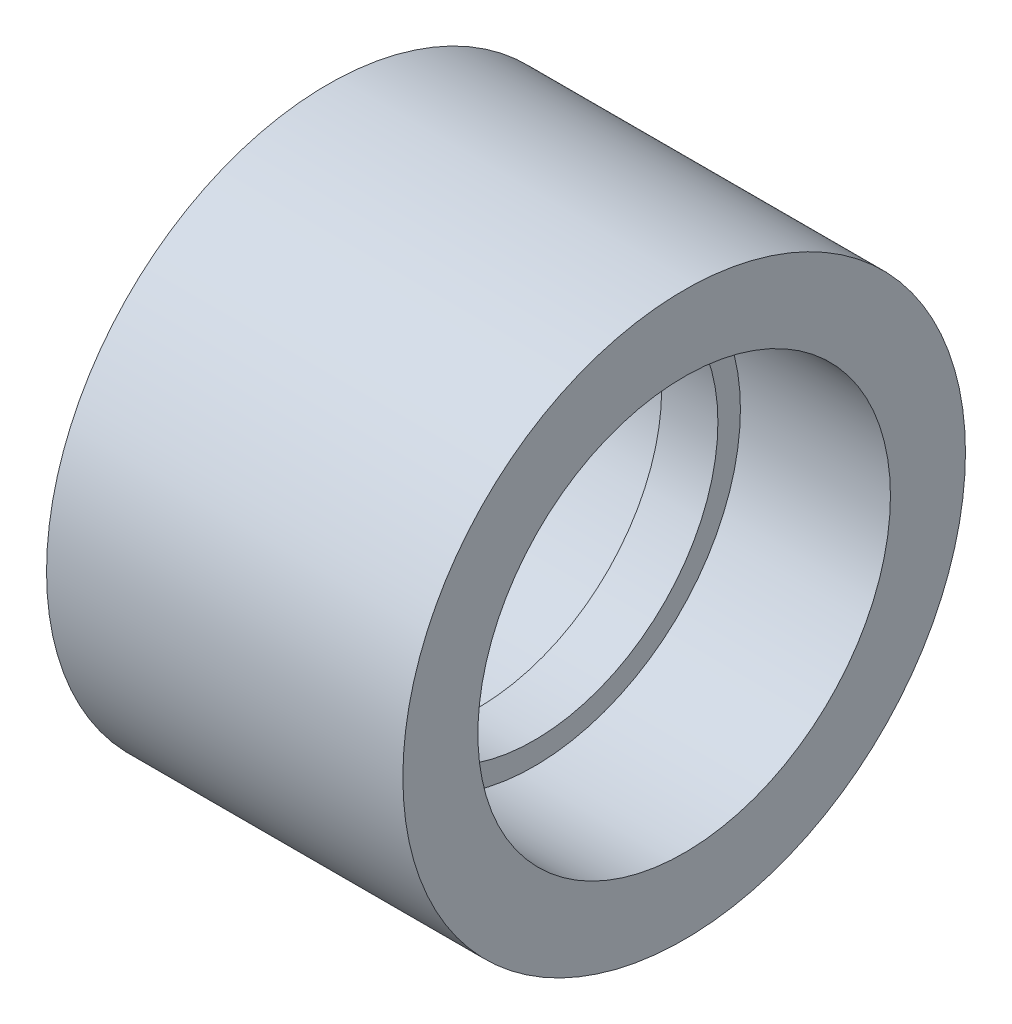
from build123d import *


with BuildPart() as part:
    # Sketch2 → Revolve1 (revolve)
    with BuildSketch(Plane(origin=(0, 0, 0), x_dir=(1, 0, 0), z_dir=(0, 1, 0))):
        Polygon((-9.5, 15), (9.5, 15), (9.5, 11), (1.5, 11), (1.5, 9.8), (-1.5, 9.8), (-1.5, 11), (-9.5, 11), align=None)
    revolve(axis=Axis((88.99, 0, 0), (-1, 0, 0)))


solid = part.part
